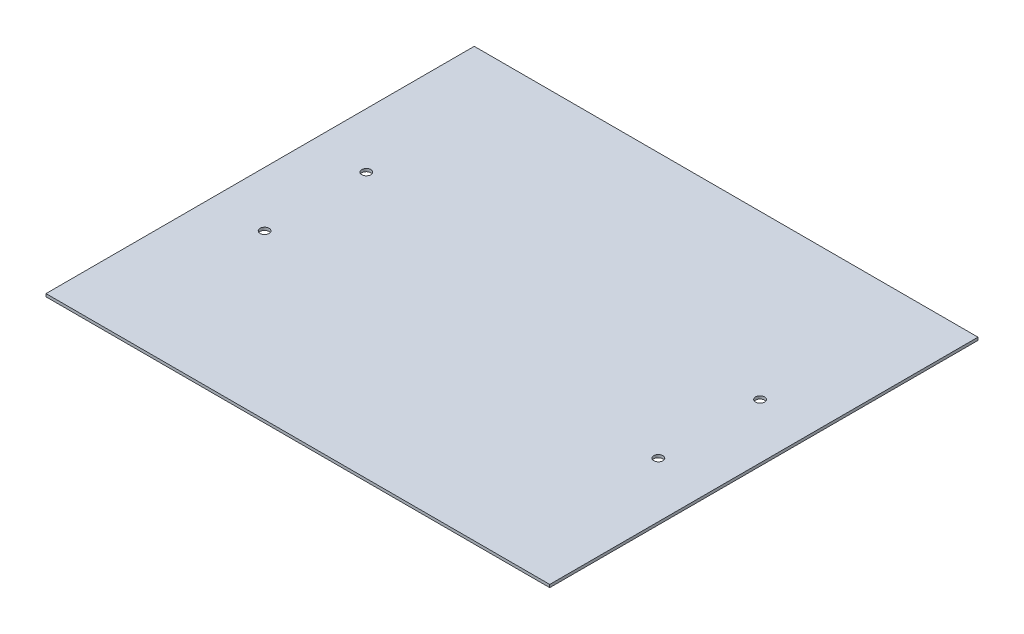
from build123d import *

# Parameters (mm, degrees)
SKETCH1_W                = 584.2
SKETCH1_H                = 502.3866
TOPPLATE_DEPTH           = 3.0734
SKETCH2_R                = 2.8956
FRONT_REARTOPHOLES_DEPTH = 4.0734
LPATTERN1_COUNT          = 4
LPATTERN1_PITCH          = 142.24
SKETCH3_R                = 2.8956
CUT_EXTRUDE2_DEPTH       = 4.0734
LPATTERN2_COUNT          = 4
LPATTERN2_PITCH          = 110.202133333
F_3_8_CLEARANCE_HOLE1_D  = 9.8044
SKETCH7_W                = 584.2
SKETCH7_H                = 502.3866
SKETCH7_W_2              = 545.9476
SKETCH7_H_2              = 464.1342
CUT_EXTRUDE3_DEPTH       = 4.0734


with BuildPart() as part:
    # Sketch1 → TopPlate (new body)
    with BuildSketch(Plane(origin=(0, 0, 0), x_dir=(1, 0, 0), z_dir=(0, 1, 0))):
        Rectangle(SKETCH1_W, SKETCH1_H)
    extrude(amount=TOPPLATE_DEPTH)

    # Sketch2 → Front/RearTopHoles (cut, through all)
    with BuildSketch(Plane(origin=(0, 3.0734, 0), x_dir=(1, 0, 0), z_dir=(0, 1, 0))):
        with Locations((-213.36, 238.5949)):
            Circle(SKETCH2_R)
        with Locations((-213.36, -237.8583)):
            Circle(SKETCH2_R)
    front_reartopholes = extrude(amount=-FRONT_REARTOPHOLES_DEPTH, mode=Mode.SUBTRACT)

    # LPattern1: Front/RearTopHoles ×4
    with Locations(*[(i * LPATTERN1_PITCH, 0, 0) for i in range(1, LPATTERN1_COUNT)]):
        add(front_reartopholes, mode=Mode.SUBTRACT)

    # Sketch3 → Cut-Extrude2 (cut, through all)
    with BuildSketch(Plane(origin=(0, 3.0734, 0), x_dir=(1, 0, 0), z_dir=(0, 1, 0))):
        with Locations((-279.5016, 165.6715)):
            Circle(SKETCH3_R)
        with Locations((279.5016, 165.6715)):
            Circle(SKETCH3_R)
    cut_extrude2 = extrude(amount=-CUT_EXTRUDE2_DEPTH, mode=Mode.SUBTRACT)

    # LPattern2: Cut-Extrude2 ×4
    with Locations(*[(0, 0, i * LPATTERN2_PITCH) for i in range(1, LPATTERN2_COUNT)]):
        add(cut_extrude2, mode=Mode.SUBTRACT)

    # 3/8 Clearance Hole1 (through all)
    with Locations(Plane(origin=(0, 3.0734, 0), x_dir=(1, 0, 0), z_dir=(0, 1, 0))):
        with Locations((-213.36, 55.469366667), (-213.36, -54.732766667), (213.36, -54.732766667), (213.36, 55.469366667)):
            Hole(F_3_8_CLEARANCE_HOLE1_D / 2)

    # Sketch7 → Cut-Extrude3 (cut, through all)
    with BuildSketch(Plane(origin=(0, 3.0734, 0), x_dir=(1, 0, 0), z_dir=(0, 1, 0))):
        Rectangle(SKETCH7_W, SKETCH7_H)
        Rectangle(SKETCH7_W_2, SKETCH7_H_2, mode=Mode.SUBTRACT)
    extrude(amount=-CUT_EXTRUDE3_DEPTH, mode=Mode.SUBTRACT)


solid = part.part
